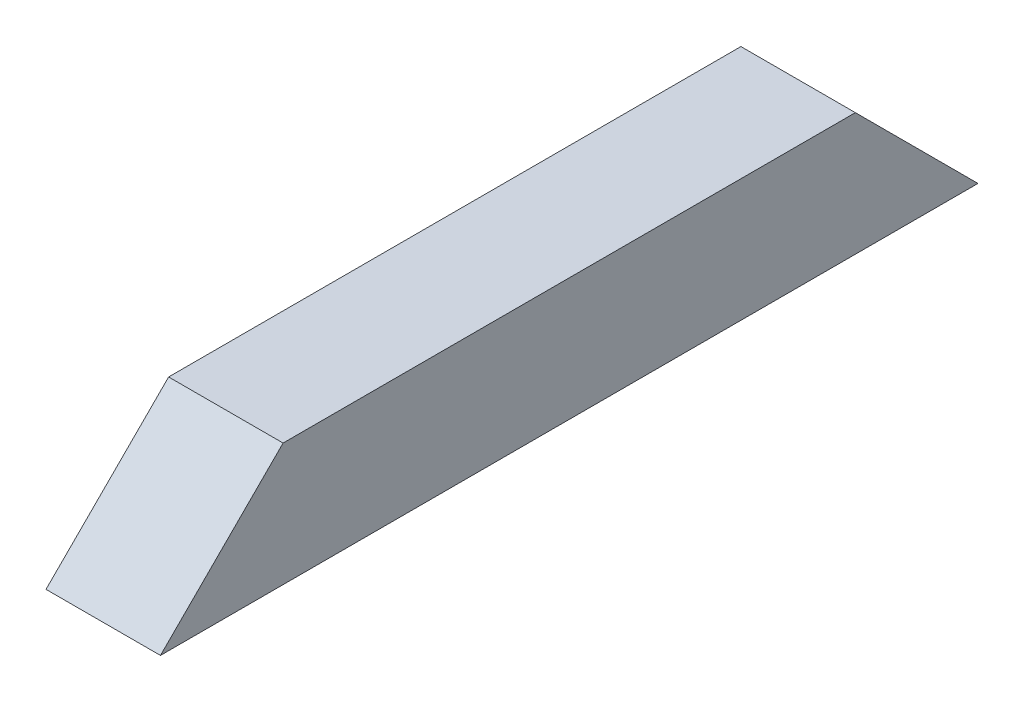
from build123d import *

# Parameters (mm, degrees)
SKETCH1_W           = 8.89
SKETCH1_H           = 63.5
BOSS_EXTRUDE1_DEPTH = 9.525
CUT_EXTRUDE1_DEPTH  = 9.89


with BuildPart() as part:
    # Sketch1 → Boss-Extrude1 (new body)
    with BuildSketch(Plane(origin=(0, 0, 0), x_dir=(1, 0, 0), z_dir=(0, 1, 0))):
        with Locations((4.445, 31.75)):
            Rectangle(SKETCH1_W, SKETCH1_H)
    extrude(amount=BOSS_EXTRUDE1_DEPTH)

    # Sketch2 → Cut-Extrude1 (cut, through all)
    with BuildSketch(Plane(origin=(8.89, 0, 0), x_dir=(0, 0, -1), z_dir=(1, 0, 0))):
        Polygon((0, 9.525), (0, 0), (9.525, 9.525), align=None)
        Polygon((63.5, 9.525), (53.975, 9.525), (63.5, 0), align=None)
    extrude(amount=-CUT_EXTRUDE1_DEPTH, mode=Mode.SUBTRACT)


solid = part.part
